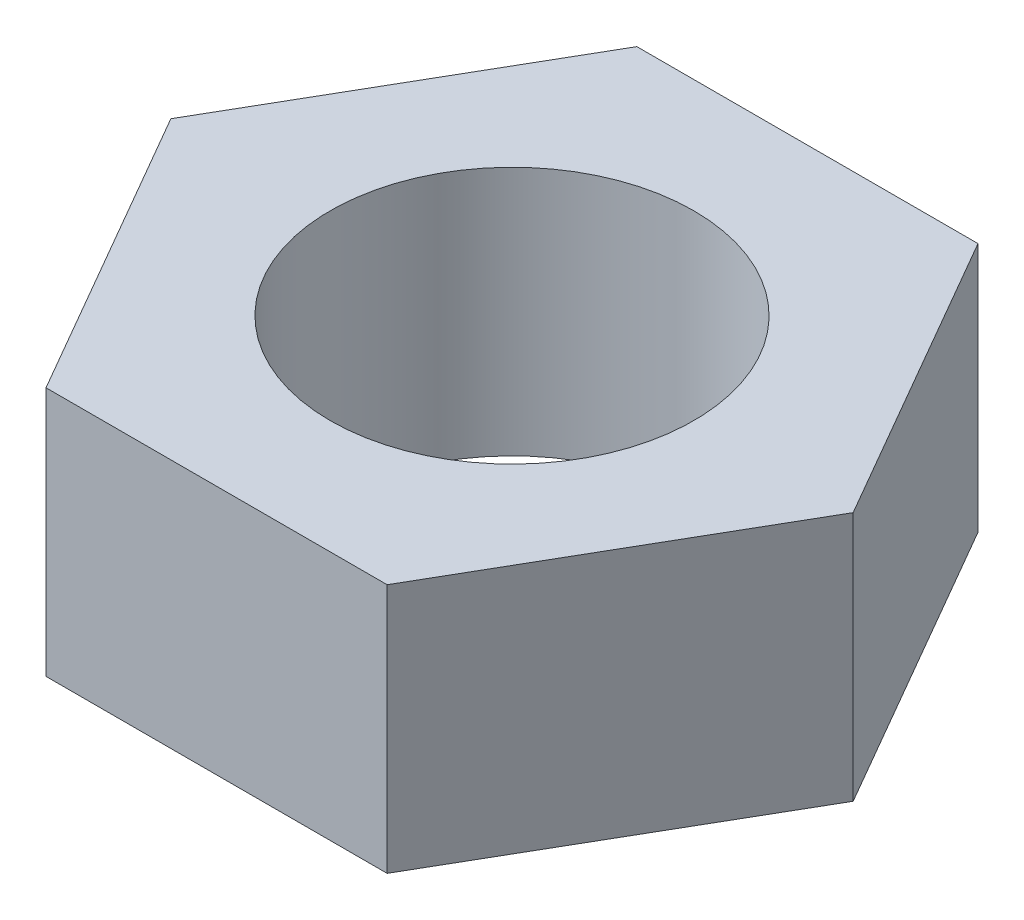
from build123d import *

# Parameters (mm, degrees)
SKETCH1_R           = 4
BOSS_EXTRUDE1_DEPTH = 5.5


with BuildPart() as part:
    # Sketch1 → Boss-Extrude1 (new body)
    with BuildSketch(Plane(origin=(0, 0, 0), x_dir=(1, 0, 0), z_dir=(0, 1, 0))):
        Polygon((-3.75277675, 6.5), (-7.505553499, 0), (-3.75277675, -6.5), (3.75277675, -6.5), (7.505553499, 0), (3.75277675, 6.5), align=None)
        Circle(SKETCH1_R, mode=Mode.SUBTRACT)
    extrude(amount=BOSS_EXTRUDE1_DEPTH)


solid = part.part
